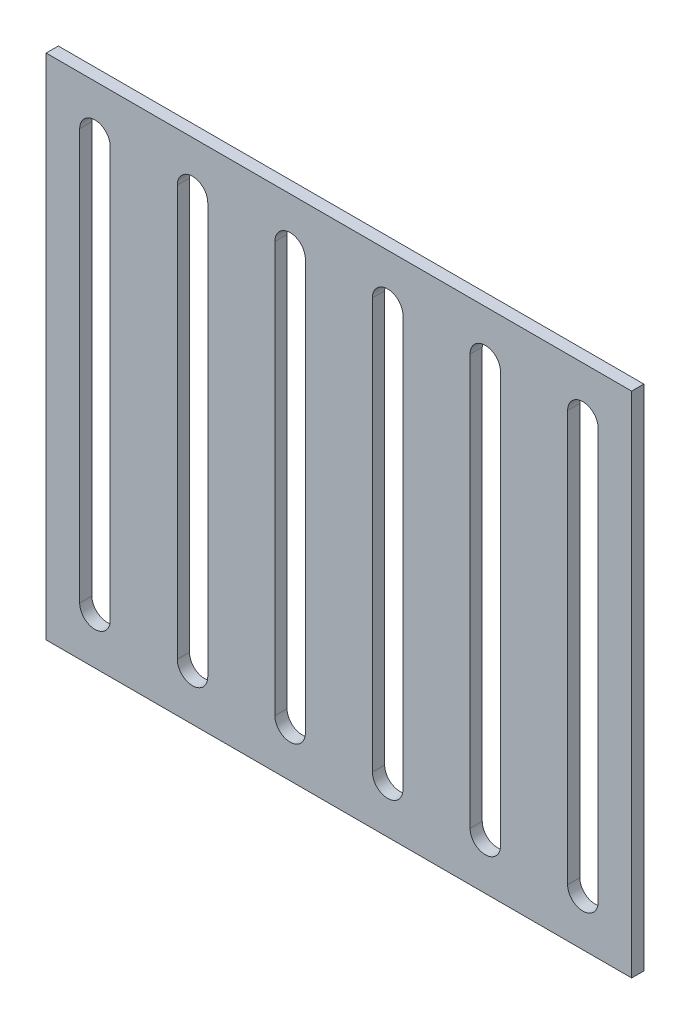
from build123d import *

# Parameters (mm, degrees)
SKETCH1_W           = 288
SKETCH1_H           = 250
BOSS_EXTRUDE1_DEPTH = 6
CUT_EXTRUDE1_DEPTH  = 7
LPATTERN4_COUNT     = 6
LPATTERN4_PITCH     = 48


with BuildPart() as part:
    # Sketch1 → Boss-Extrude1 (new body)
    with BuildSketch(Plane.XY):
        with Locations((144, 125)):
            Rectangle(SKETCH1_W, SKETCH1_H)
    extrude(amount=BOSS_EXTRUDE1_DEPTH)

    # Sketch2 → Cut-Extrude1 (cut, through all)
    with BuildSketch(Plane.XY.offset(6)):
        with BuildLine():
            Line((16.5, 24), (16.5, 226))
            ThreePointArc((16.5, 226), (24, 233.5), (31.5, 226))
            Line((31.5, 226), (31.5, 24))
            ThreePointArc((31.5, 24), (24, 16.5), (16.5, 24))
        make_face()
    cut_extrude1 = extrude(amount=-CUT_EXTRUDE1_DEPTH, mode=Mode.SUBTRACT)

    # LPattern4: Cut-Extrude1 ×6
    with Locations(*[(i * LPATTERN4_PITCH, 0, 0) for i in range(1, LPATTERN4_COUNT)]):
        add(cut_extrude1, mode=Mode.SUBTRACT)


solid = part.part
